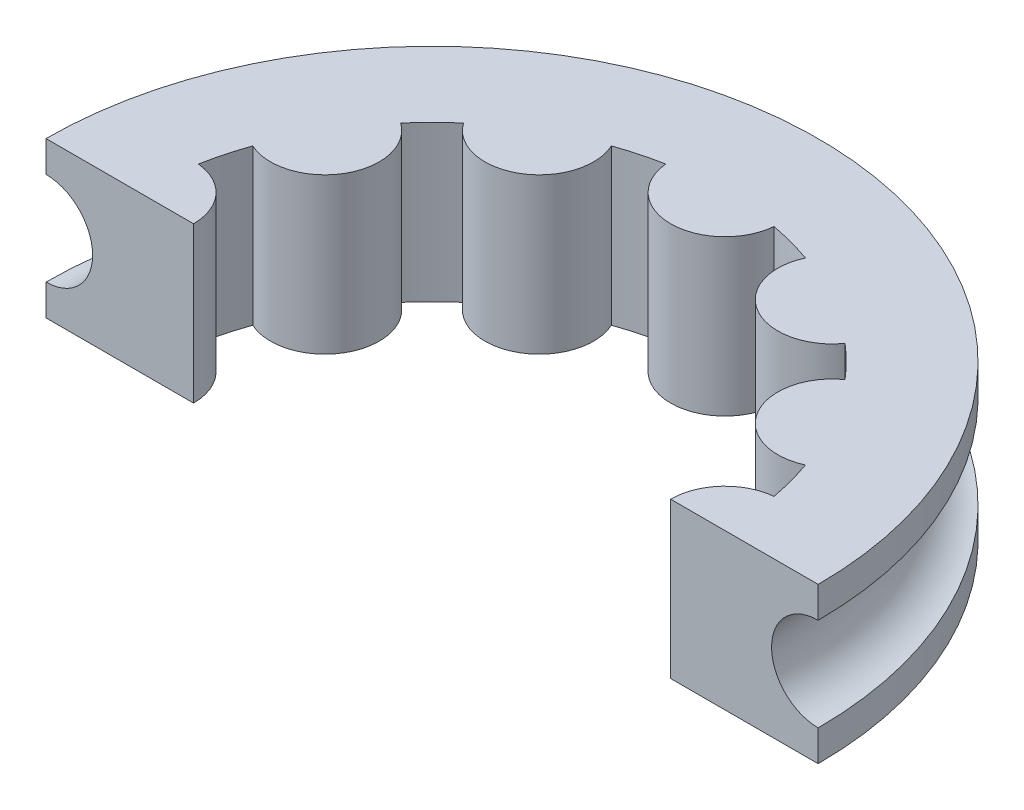
from build123d import *

# Parameters (mm, degrees)
SKETCH1_R           = 12.427436065
BOSS_EXTRUDE1_DEPTH = 5
CUT_EXTRUDE1_DEPTH  = 6
SKETCH8_R           = 1.5


with BuildPart() as part:
    # Sketch1 → Boss-Extrude1 (new body)
    with BuildSketch(Plane(origin=(0, 0, 0), x_dir=(1, 0, 0), z_dir=(0, 1, 0))):
        with Locations((-0.572563935, 0)):
            Circle(SKETCH1_R)
        with BuildLine():
            ThreePointArc((-9.837575138, 1.742446029), (-9.678767906, 2.44), (-9.467522018, 3.123503075))
            ThreePointArc((-9.467522018, 3.123503075), (-7.221418603, 3.838718032), (-7.725075989, 6.141508127))
            ThreePointArc((-7.725075989, 6.141508127), (-7.238767906, 6.66620397), (-6.714072063, 7.152512053))
            ThreePointArc((-6.714072063, 7.152512053), (-4.411281968, 6.648854668), (-3.696067011, 8.894958082))
            ThreePointArc((-3.696067011, 8.894958082), (-3.012563935, 9.10620397), (-2.315009965, 9.265011203))
            ThreePointArc((-2.315009965, 9.265011203), (-0.572563935, 7.677436065), (1.169882094, 9.265011203))
            ThreePointArc((1.169882094, 9.265011203), (1.867436065, 9.10620397), (2.55093914, 8.894958082))
            ThreePointArc((2.55093914, 8.894958082), (3.266154097, 6.648854668), (5.568944192, 7.152512053))
            ThreePointArc((5.568944192, 7.152512053), (6.093640035, 6.66620397), (6.579948118, 6.141508127))
            ThreePointArc((6.579948118, 6.141508127), (6.076290732, 3.838718032), (8.322394147, 3.123503075))
            ThreePointArc((8.322394147, 3.123503075), (8.533640035, 2.44), (8.692447267, 1.742446029))
            ThreePointArc((8.692447267, 1.742446029), (7.104872129, 0), (8.692447267, -1.742446029))
            ThreePointArc((8.692447267, -1.742446029), (8.533640035, -2.44), (8.322394147, -3.123503075))
            ThreePointArc((8.322394147, -3.123503075), (6.076290732, -3.838718032), (6.579948118, -6.141508127))
            ThreePointArc((6.579948118, -6.141508127), (6.093640035, -6.66620397), (5.568944192, -7.152512053))
            ThreePointArc((5.568944192, -7.152512053), (3.266154097, -6.648854668), (2.55093914, -8.894958082))
            ThreePointArc((2.55093914, -8.894958082), (1.867436065, -9.10620397), (1.169882094, -9.265011203))
            ThreePointArc((1.169882094, -9.265011203), (-0.572563935, -7.677436065), (-2.315009965, -9.265011203))
            ThreePointArc((-2.315009965, -9.265011203), (-3.012563935, -9.10620397), (-3.696067011, -8.894958082))
            ThreePointArc((-3.696067011, -8.894958082), (-4.411281968, -6.648854668), (-6.714072063, -7.152512053))
            ThreePointArc((-6.714072063, -7.152512053), (-7.238767906, -6.66620397), (-7.725075989, -6.141508127))
            ThreePointArc((-7.725075989, -6.141508127), (-7.221418603, -3.838718032), (-9.467522018, -3.123503075))
            ThreePointArc((-9.467522018, -3.123503075), (-9.678767906, -2.44), (-9.837575138, -1.742446029))
            ThreePointArc((-9.837575138, -1.742446029), (-8.25, 0), (-9.837575138, 1.742446029))
        make_face(mode=Mode.SUBTRACT)
    extrude(amount=BOSS_EXTRUDE1_DEPTH)

    # Sketch7 → Cut-Extrude1 (cut, through all)
    with BuildSketch(Plane(origin=(0, 5, 0), x_dir=(1, 0, 0), z_dir=(0, 1, 0))):
        Polygon((13.300548716, 0), (-14.205268785, 0), (-13.392288958, -15.44944458), (9.438894535, -14.771961391), align=None)
    extrude(amount=-CUT_EXTRUDE1_DEPTH, mode=Mode.SUBTRACT)

    # Sketch8 → Cut-Revolve2 (revolve, cut)
    with BuildSketch(Plane.XY):
        with Locations((11.854872129, 2.5)):
            Circle(SKETCH8_R)
    revolve(axis=Axis((-0.572563935, 5, 0), (0, -1, 0)), mode=Mode.SUBTRACT)


solid = part.part
